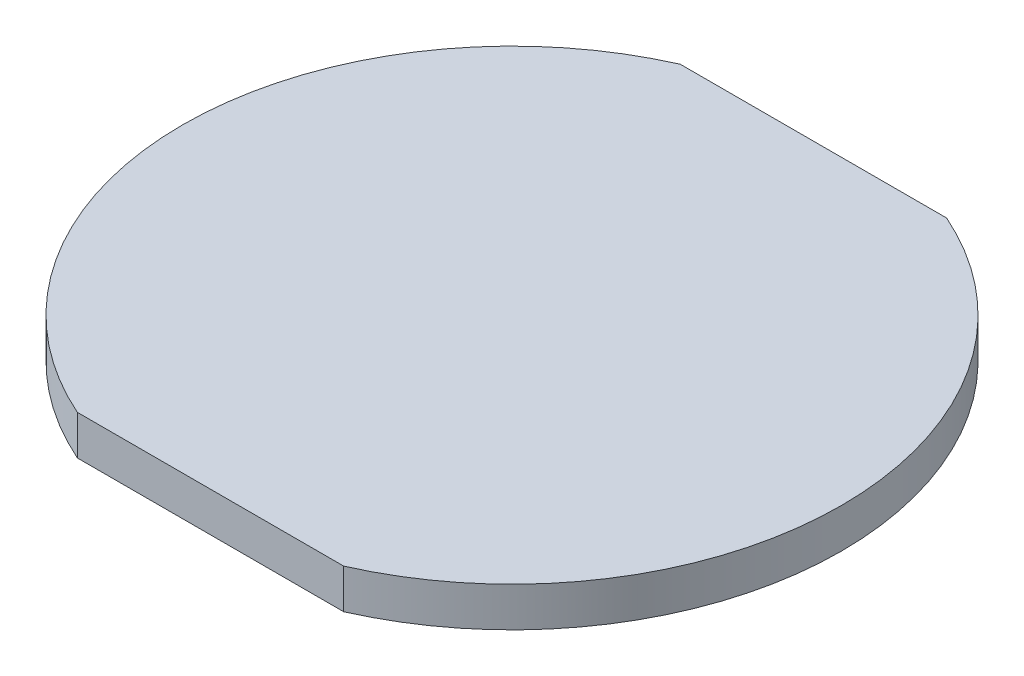
from build123d import *

# Parameters (mm, degrees)
BOSS_EXTRUDE1_DEPTH = 3


with BuildPart() as part:
    # Sketch1 → Boss-Extrude1 (new body)
    with BuildSketch(Plane(origin=(0, 0, 0), x_dir=(1, 0, 0), z_dir=(0, 1, 0))):
        with BuildLine():
            Line((10.1, -22.868974616), (-10.1, -22.868974616))
            ThreePointArc((-10.1, -22.868974616), (-25, 0), (-10.1, 22.868974616))
            Line((-10.1, 22.868974616), (10.1, 22.868974616))
            ThreePointArc((10.1, 22.868974616), (25, 0), (10.1, -22.868974616))
        make_face()
    extrude(amount=BOSS_EXTRUDE1_DEPTH)


solid = part.part
